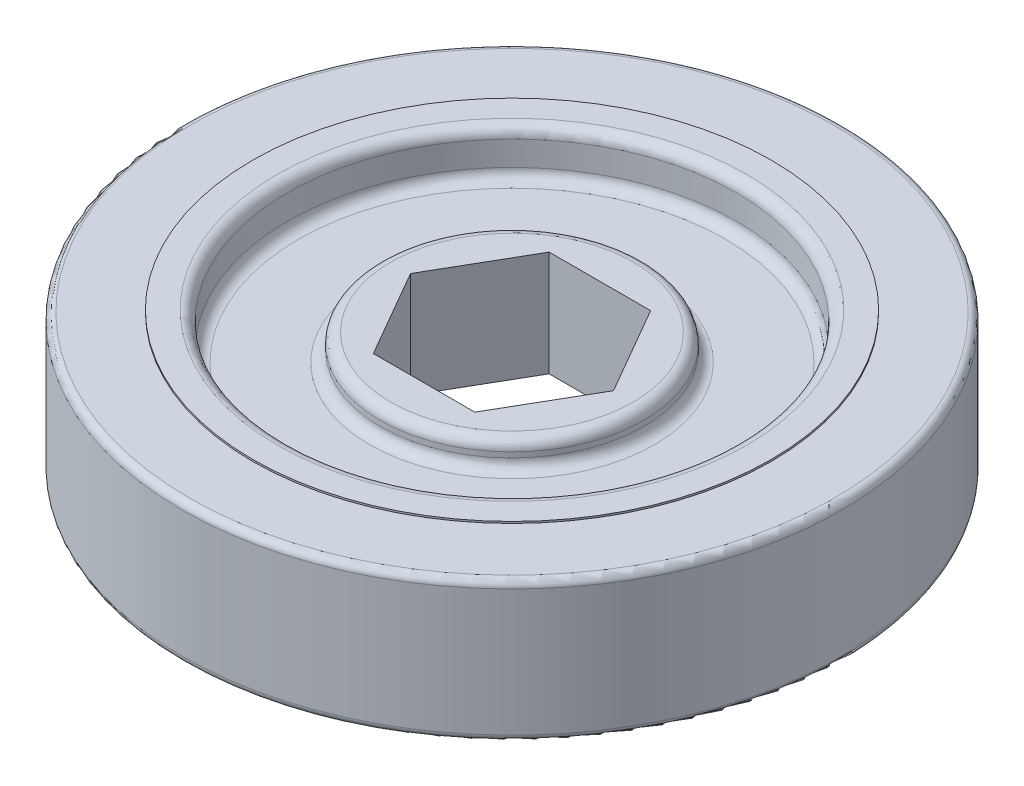
from build123d import *

# Parameters (mm, degrees)
SKETCH1_R           = 23.8125
SKETCH1_R_2         = 18.7325
BOSS_EXTRUDE1_DEPTH = 5.08
SKETCH1_3_R         = 18.7325
SKETCH1_3_R_2       = 16.1925
BOSS_EXTRUDE2_DEPTH = 5.207
SKETCH1_4_R         = 9.525
BOSS_EXTRUDE3_DEPTH = 3.81
SKETCH1_5_R         = 16.1925
SKETCH1_5_R_2       = 9.525
BOSS_EXTRUDE4_DEPTH = 1.905
FILLET1_R           = 0.762
FILLET2_R           = 0.508


with BuildPart() as part:
    # Sketch1 → Boss-Extrude1 (new, symmetric)
    with BuildSketch(Plane(origin=(0, 0, 0), x_dir=(1, 0, 0), z_dir=(0, 1, 0))):
        Circle(SKETCH1_R)
        Circle(SKETCH1_R_2, mode=Mode.SUBTRACT)
    extrude(amount=BOSS_EXTRUDE1_DEPTH, both=True)

    # Sketch1_3 → Boss-Extrude2 (add, symmetric)
    with BuildSketch(Plane(origin=(0, 0, 0), x_dir=(1, 0, 0), z_dir=(0, 1, 0))):
        Circle(SKETCH1_3_R)
        Circle(SKETCH1_3_R_2, mode=Mode.SUBTRACT)
    extrude(amount=BOSS_EXTRUDE2_DEPTH, both=True)



with BuildPart() as body_2:
    # Sketch1_4 → Boss-Extrude3 (new, symmetric)
    with BuildSketch(Plane(origin=(0, 0, 0), x_dir=(1, 0, 0), z_dir=(0, 1, 0))):
        Circle(SKETCH1_4_R)
        Polygon((-3.666174209, 6.35), (3.666174209, 6.35), (7.332348419, 0), (3.666174209, -6.35), (-3.666174209, -6.35), (-7.332348419, 0), align=None, mode=Mode.SUBTRACT)
    extrude(amount=BOSS_EXTRUDE3_DEPTH, both=True)


with BuildPart() as part_1:
    add(part.part)

    add(body_2.part)  # Boss-Extrude4 merges body 2
    # Sketch1_5 → Boss-Extrude4 (add, symmetric)
    with BuildSketch(Plane(origin=(0, 0, 0), x_dir=(1, 0, 0), z_dir=(0, 1, 0))):
        Circle(SKETCH1_5_R)
        Circle(SKETCH1_5_R_2, mode=Mode.SUBTRACT)
    extrude(amount=BOSS_EXTRUDE4_DEPTH, both=True)

    # Fillet1
    fillet1_edges = [part_1.edges().sort_by_distance(p)[0] for p in [
        (-16.1925, -1.905, 0),
        (-16.1925, 5.207, 0),
        (-16.1925, 1.905, 0),
        (-9.525, 3.81, 0),
        (-9.525, 1.905, 0),
        (-16.1925, -5.207, 0),
        (-9.525, -3.81, 0),
        (-9.525, -1.905, 0),
    ]]
    fillet(fillet1_edges, radius=FILLET1_R)

    # Fillet2
    fillet2_edges = [part_1.edges().sort_by_distance(p)[0] for p in [
        (-23.8125, -5.08, 0),
        (-23.8125, 5.08, 0),
    ]]
    fillet(fillet2_edges, radius=FILLET2_R)


solid = part_1.part
